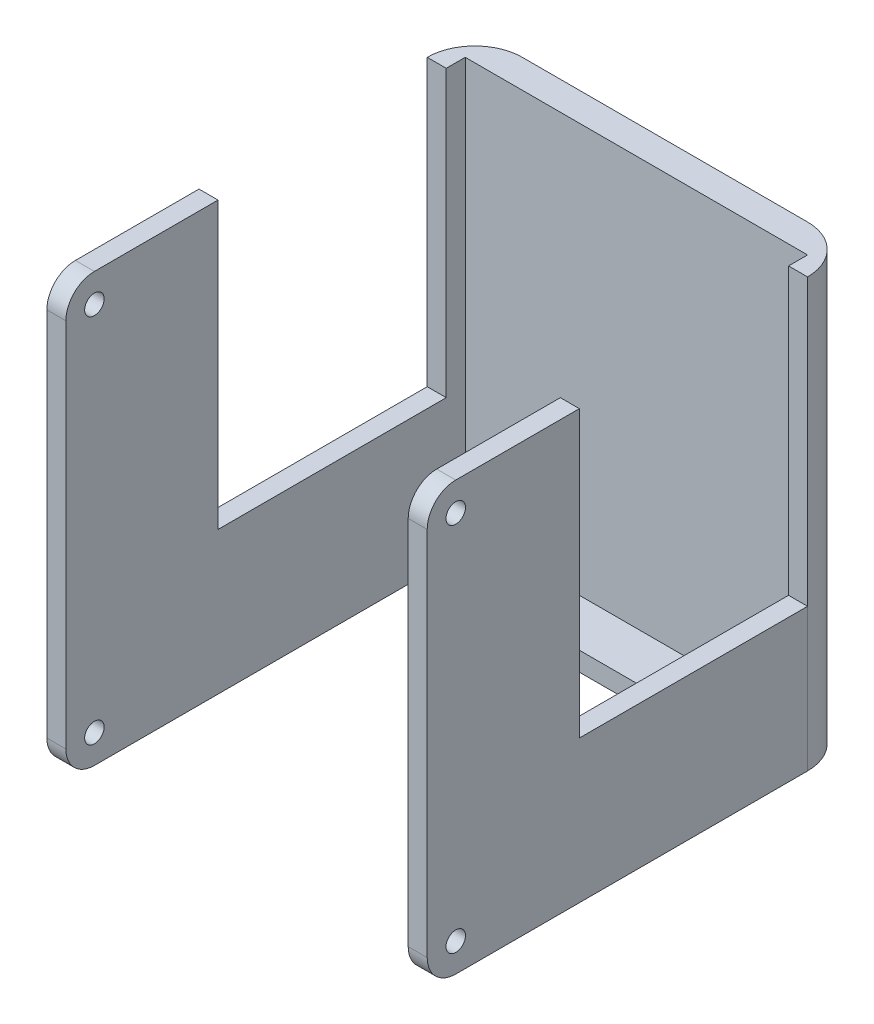
from build123d import *

# Parameters (mm, degrees)
SKETCH_1_W           = 40
SKETCH_1_H           = 45
EXTRUDE_1_DEPTH      = 40
EXTRUDE_1_DEPTH_BACK = 5
SKETCH_2_W           = 36
SKETCH_2_H           = 37
CUT_EXTRUDE_1_DEPTH  = 50
SKETCH_3_R           = 1.025
CUT_EXTRUDE_2_DEPTH  = 2
SKETCH_4_R           = 1.025
CUT_EXTRUDE_3_DEPTH  = 2
SKETCH_5_W           = 36
SKETCH_5_H           = 5
CUT_EXTRUDE_4_DEPTH  = 43
FILLET_6_R           = 5
FILLET_7_R           = 5
FILLET_12_R          = 3
FILLET_13_R          = 3
FILLET_14_R          = 3
FILLET_15_R          = 3
SKETCH_6_W           = 24
SKETCH_6_H           = 30
CUT_EXTRUDE_5_DEPTH  = 44


with BuildPart() as part:
    # 草圖1 → 填料-伸長1 (new body, two sides)
    with BuildSketch(Plane.XY) as extrude_1_sk:
        with Locations((5.454545455, -5.590909091)):
            Rectangle(SKETCH_1_W, SKETCH_1_H)
    extrude(amount=EXTRUDE_1_DEPTH)
    extrude(extrude_1_sk.sketch, amount=-EXTRUDE_1_DEPTH_BACK)

    # 草圖2 → 除料-伸長1 (cut)
    with BuildSketch(Plane(origin=(0, 16.909090909, 0), x_dir=(1, 0, 0), z_dir=(0, 1, 0))):
        with Locations((5.454545455, -21.5)):
            Rectangle(SKETCH_2_W, SKETCH_2_H)
    extrude(amount=-CUT_EXTRUDE_1_DEPTH, mode=Mode.SUBTRACT)

    # 草圖3 → 除料-伸長2 (cut)
    with BuildSketch(Plane.ZY.offset(14.545454545)):
        with Locations((37, -25.090909091)):
            Circle(SKETCH_3_R)
        with Locations((37, 13.909090909)):
            Circle(SKETCH_3_R)
    extrude(amount=-CUT_EXTRUDE_2_DEPTH, mode=Mode.SUBTRACT)

    # 草圖4 → 除料-伸長3 (cut)
    with BuildSketch(Plane(origin=(25.454545455, 0, 0), x_dir=(0, 0, -1), z_dir=(1, 0, 0))):
        with Locations((-37, 13.909090909)):
            Circle(SKETCH_4_R)
        with Locations((-37, -25.090909091)):
            Circle(SKETCH_4_R)
    extrude(amount=-CUT_EXTRUDE_3_DEPTH, mode=Mode.SUBTRACT)

    # 草圖5 → 除料-伸長4 (cut)
    with BuildSketch(Plane(origin=(0, 16.909090909, 0), x_dir=(1, 0, 0), z_dir=(0, 1, 0))):
        with Locations((5.454545455, -0.5)):
            Rectangle(SKETCH_5_W, SKETCH_5_H)
    extrude(amount=-CUT_EXTRUDE_4_DEPTH, mode=Mode.SUBTRACT)

    # 圓角6
    fillet_6_edges = [part.edges().sort_by_distance(p)[0] for p in [
        (-14.545454545, -5.590909091, -5),
    ]]
    fillet(fillet_6_edges, radius=FILLET_6_R)

    # 圓角7
    fillet_7_edges = [part.edges().sort_by_distance(p)[0] for p in [
        (25.454545455, -5.590909091, -5),
    ]]
    fillet(fillet_7_edges, radius=FILLET_7_R)

    # 圓角12
    fillet_12_edges = [part.edges().sort_by_distance(p)[0] for p in [
        (-13.545454545, -28.090909091, 40),
    ]]
    fillet(fillet_12_edges, radius=FILLET_12_R)

    # 圓角13
    fillet_13_edges = [part.edges().sort_by_distance(p)[0] for p in [
        (24.454545455, -28.090909091, 40),
    ]]
    fillet(fillet_13_edges, radius=FILLET_13_R)

    # 圓角14
    fillet_14_edges = [part.edges().sort_by_distance(p)[0] for p in [
        (-13.545454545, 16.909090909, 40),
    ]]
    fillet(fillet_14_edges, radius=FILLET_14_R)

    # 圓角15
    fillet_15_edges = [part.edges().sort_by_distance(p)[0] for p in [
        (24.454545455, 16.909090909, 40),
    ]]
    fillet(fillet_15_edges, radius=FILLET_15_R)

    # 草圖6 → 除料-伸長5 (cut)
    with BuildSketch(Plane.ZY.offset(14.545454545)):
        with Locations((12, 1.909090909)):
            Rectangle(SKETCH_6_W, SKETCH_6_H)
    extrude(amount=-CUT_EXTRUDE_5_DEPTH, mode=Mode.SUBTRACT)


solid = part.part
